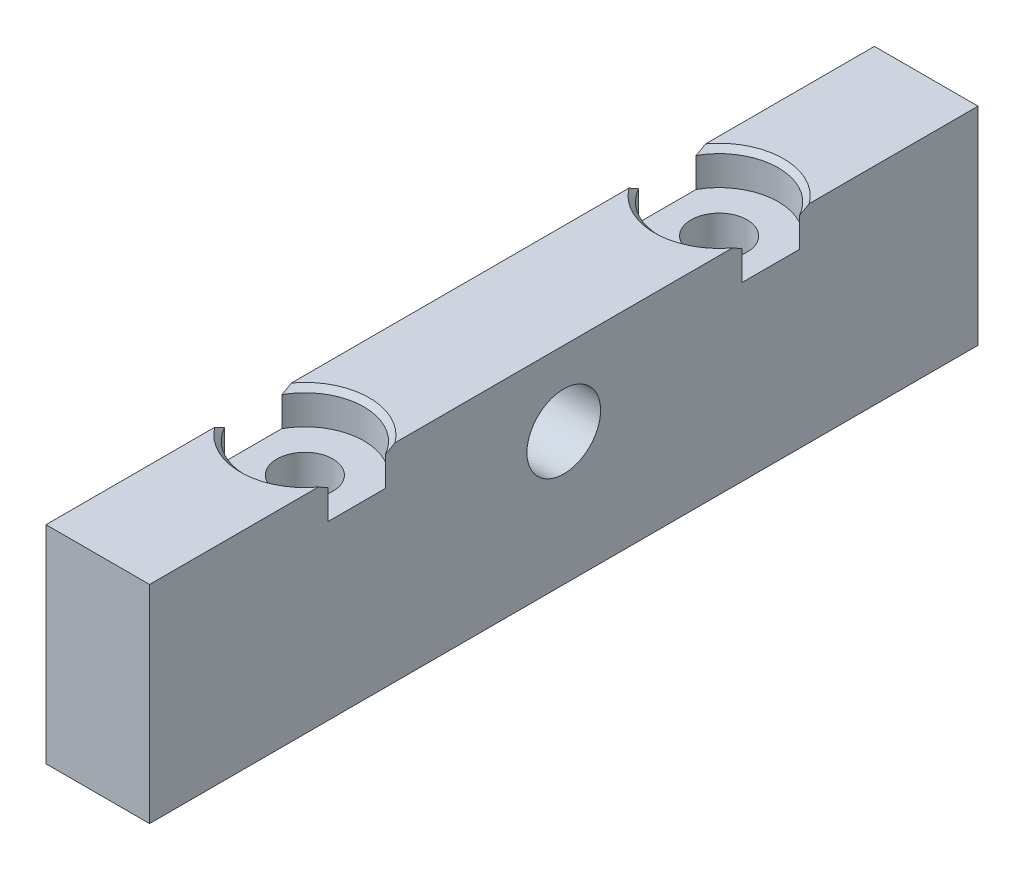
from build123d import *

# Parameters (mm, degrees)
SKETCH1_W                                    = 12.5
SKETCH1_H                                    = 100
BOSS_EXTRUDE1_DEPTH                          = 25
CBORE_FOR_1_4_BINDING_HEAD_MACHINE_S_2_COUNT = 2
CBORE_FOR_1_4_BINDING_HEAD_MACHINE_S_2_PITCH = 50
CUT_EXTRUDE1_REACH                           = 14.5
SKETCH4_R                                    = 4.445


with BuildPart() as part:
    # Sketch1 → Boss-Extrude1 (new body)
    with BuildSketch(Plane(origin=(0, 0, 0), x_dir=(1, 0, 0), z_dir=(0, 1, 0))):
        with Locations((1.425031038, -32.088839839)):
            Rectangle(SKETCH1_W, SKETCH1_H)
    extrude(amount=BOSS_EXTRUDE1_DEPTH)

    # Sketch3 → CBORE for 1/4 Binding Head Machine Screw1 (revolve, cut)
    with BuildSketch(Plane(origin=(1.425031038, 25, 7.088839839), x_dir=(0, 0, 1), z_dir=(1, 0, 0))):
        Polygon((0, 0), (0, 25), (3.3782, 25), (3.3782, 4.191), (7.14375, 4.191), (7.14375, 0.635), (7.77875, 0), align=None)
    cbore_for_1_4_binding_head_machine_screw = revolve(axis=Axis((1.425031038, 31.35, 7.088839839), (0, -1, 0)), mode=Mode.SUBTRACT)

    # CBORE for 1_4 Binding Head Machine S 2: CBORE for 1/4 Binding Head Machine Screw1 ×2
    with Locations(*[(0, 0, i * CBORE_FOR_1_4_BINDING_HEAD_MACHINE_S_2_PITCH) for i in range(1, CBORE_FOR_1_4_BINDING_HEAD_MACHINE_S_2_COUNT)]):
        add(cbore_for_1_4_binding_head_machine_screw, mode=Mode.SUBTRACT)

    # Sketch4 → Cut-Extrude1 (cut, up to next)
    with BuildSketch(Plane.ZY.offset(4.824968962), mode=Mode.PRIVATE) as cut_extrude1_sk1:
        with Locations((32.088839839, 16)):
            Circle(SKETCH4_R)
    cut_extrude1_tool1 = extrude(cut_extrude1_sk1.sketch, amount=-CUT_EXTRUDE1_REACH, mode=Mode.PRIVATE) & part.part
    add(cut_extrude1_tool1.solids().sort_by_distance((-4.824969, 16, 32.08884))[0], mode=Mode.SUBTRACT)


solid = part.part
